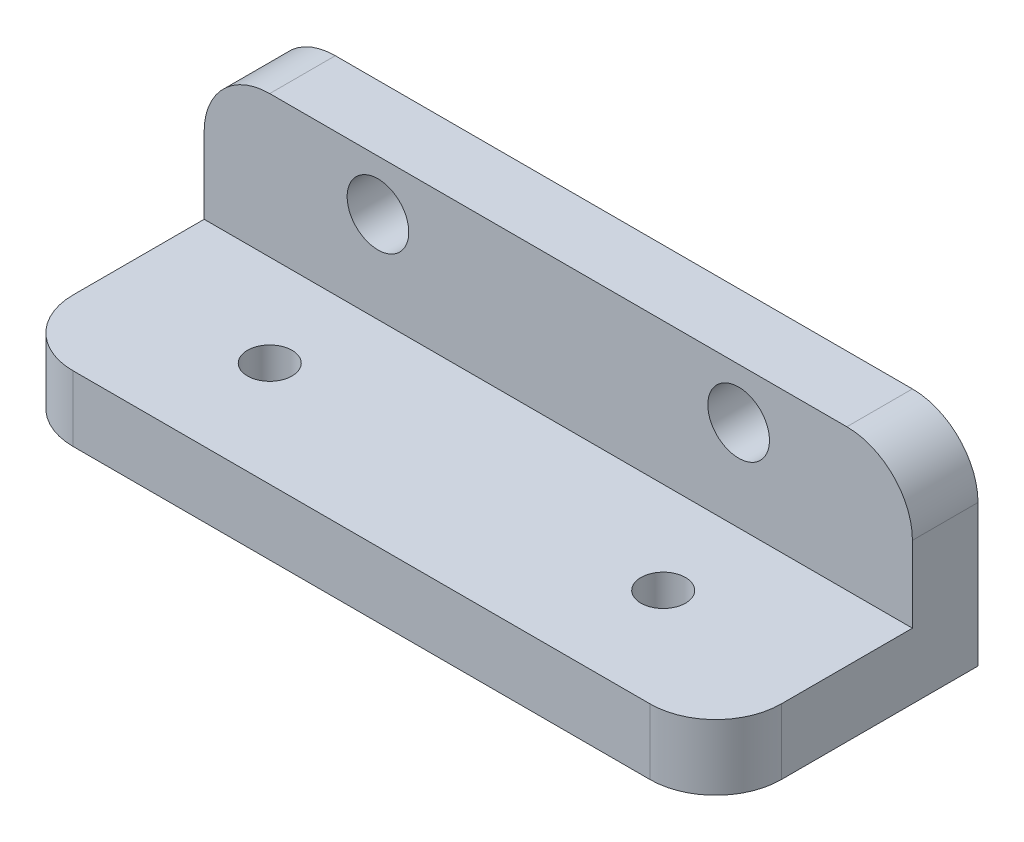
from build123d import *

# Parameters (mm, degrees)
SKETCH1_W                = 54
SKETCH1_H                = 20
BOSS_EXTRUDE1_DEPTH      = 5
SKETCH2_W                = 54
SKETCH2_H                = 5
BOSS_EXTRUDE2_DEPTH      = 10.8
M3_CLEARANCE_HOLE1_D     = 3.4
M3_CLEARANCE_HOLE1_DEPTH = 28.71
M3_CLEARANCE_HOLE1_TIP   = 1.021463052
M3_CLEARANCE_HOLE2_D     = 3.4
FILLET1_R                = 5
SKETCH11_R               = 2.35
CUT_EXTRUDE4_DEPTH       = 7.8
SKETCH9_R                = 2.35
CUT_EXTRUDE5_DEPTH       = 7.8


with BuildPart() as part:
    # Sketch1 → Boss-Extrude1 (new body)
    with BuildSketch(Plane(origin=(0, 0, 0), x_dir=(1, 0, 0), z_dir=(0, 1, 0))):
        Rectangle(SKETCH1_W, SKETCH1_H)
    extrude(amount=BOSS_EXTRUDE1_DEPTH)

    # Sketch2 → Boss-Extrude2 (add)
    with BuildSketch(Plane(origin=(0, 5, 0), x_dir=(1, 0, 0), z_dir=(0, 1, 0))):
        with Locations((0, 7.5)):
            Rectangle(SKETCH2_W, SKETCH2_H)
    extrude(amount=BOSS_EXTRUDE2_DEPTH)

    # M3 Clearance Hole1
    with Locations(Plane.XY.offset(-5)):
        with Locations((-13.75, 12.6), (13.75, 12.6)):
            Hole(M3_CLEARANCE_HOLE1_D / 2, depth=M3_CLEARANCE_HOLE1_DEPTH)
            with Locations((0, 0, -(M3_CLEARANCE_HOLE1_DEPTH + M3_CLEARANCE_HOLE1_TIP / 2))):  # 118° drill point
                Cone(0, M3_CLEARANCE_HOLE1_D / 2, M3_CLEARANCE_HOLE1_TIP, mode=Mode.SUBTRACT)

    # M3 Clearance Hole2 (through all)
    with Locations(Plane(origin=(0, 5, 0), x_dir=(1, 0, 0), z_dir=(0, 1, 0))):
        with Locations((15, -2), (-15, -2)):
            Hole(M3_CLEARANCE_HOLE2_D / 2)

    # Fillet1
    fillet1_edges = [part.edges().sort_by_distance(p)[0] for p in [
        (27, 2.5, 10),
        (-27, 2.5, 10),
        (27, 15.8, -7.5),
        (-27, 15.8, -7.5),
    ]]
    fillet(fillet1_edges, radius=FILLET1_R)

    # Sketch11 → Cut-Extrude4 (cut)
    with BuildSketch(Plane(origin=(0, 0, -10), x_dir=(-1, 0, 0), z_dir=(0, 0, -1))):
        with Locations((-13.75, 11.95)):
            Circle(SKETCH11_R)
    extrude(amount=-CUT_EXTRUDE4_DEPTH, mode=Mode.SUBTRACT)

    # Sketch9 → Cut-Extrude5 (cut)
    with BuildSketch(Plane(origin=(0, 0, -10), x_dir=(-1, 0, 0), z_dir=(0, 0, -1))):
        with Locations((13.75, 11.95)):
            Circle(SKETCH9_R)
    extrude(amount=-CUT_EXTRUDE5_DEPTH, mode=Mode.SUBTRACT)


solid = part.part
